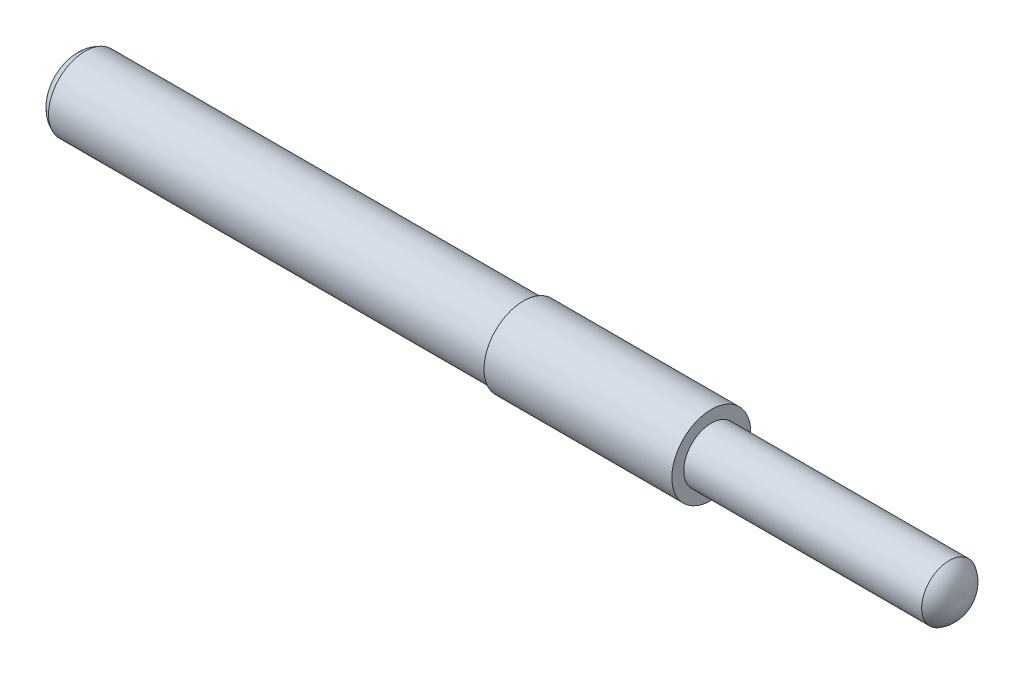
from build123d import *


with BuildPart() as part:
    # Sketch4 → Revolve5 (revolve)
    with BuildSketch(Plane.XY):
        with BuildLine():
            Line((50, 0), (30, 0))
            Line((30, 0), (30, -2.2))
            Line((30, -2.2), (49, -2.2))
            ThreePointArc((49, -2.2), (49.854727227, -1.261239649), (50, 0))
        make_face()
        Polygon((30, 0), (15, 0), (15, -2.925), (15, -3.15), (30, -3.15), (30, -2.2), align=None)
        with BuildLine():
            Line((15, 0), (-20, 0))
            ThreePointArc((-20, 0), (-21.025452167, -1.4625), (-20, -2.925))
            Line((-20, -2.925), (15, -2.925))
            Line((15, -2.925), (15, 0))
        make_face()
    revolve(axis=Axis((-50, 0, 0), (1, 0, 0)))


solid = part.part
